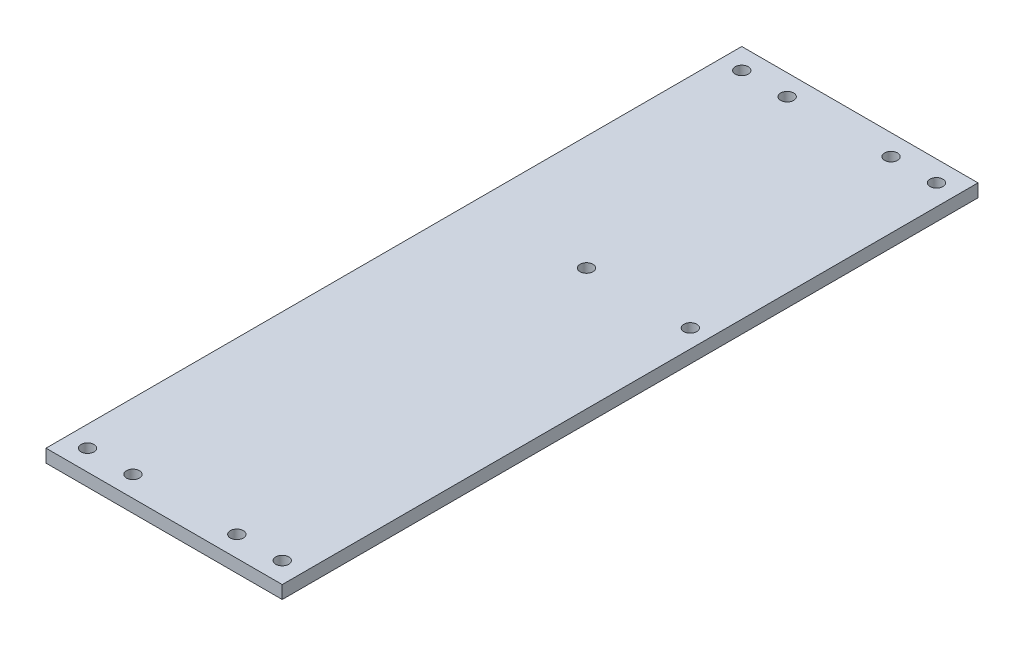
from build123d import *

# Parameters (mm, degrees)
SKIZZE1_W                       = 72.5
SKIZZE1_H                       = 268
AUFSATZ_LINEAR_AUSTRAGEN1_DEPTH = 5
M6_GEWINDEBOHRUNG2_D            = 5
M6_GEWINDEBOHRUNG2_DEPTH        = 5
M6_GEWINDEBOHRUNG1_D            = 5
M6_GEWINDEBOHRUNG1_DEPTH        = 5
SKIZZE7_W                       = 268
SKIZZE7_H                       = 5
AUFSATZ_LINEAR_AUSTRAGEN2_DEPTH = 18.5
M6_GEWINDEBOHRUNG3_D            = 5
M6_GEWINDEBOHRUNG3_DEPTH        = 5


with BuildPart() as part:
    # Skizze1 → Aufsatz-Linear austragen1 (new body)
    with BuildSketch(Plane(origin=(0, 0, 0), x_dir=(1, 0, 0), z_dir=(0, 1, 0))):
        Rectangle(SKIZZE1_W, SKIZZE1_H)
    extrude(amount=AUFSATZ_LINEAR_AUSTRAGEN1_DEPTH)

    # M6 Gewindebohrung2
    with Locations(Plane(origin=(0, 5, 0), x_dir=(1, 0, 0), z_dir=(0, 1, 0))):
        with Locations((-29.25, -126), (10.75, -126), (-29.25, 126), (10.75, 126)):
            Hole(M6_GEWINDEBOHRUNG2_D / 2, depth=M6_GEWINDEBOHRUNG2_DEPTH)

    # M6 Gewindebohrung1
    with Locations(Plane(origin=(0, 5, 0), x_dir=(1, 0, 0), z_dir=(0, 1, 0))):
        with Locations((29.25, 30.2), (-10.75, 30.2)):
            Hole(M6_GEWINDEBOHRUNG1_D / 2, depth=M6_GEWINDEBOHRUNG1_DEPTH)

    # Skizze7 → Aufsatz-Linear austragen2 (add)
    with BuildSketch(Plane.ZY.offset(36.25)):
        with Locations((0, 2.5)):
            Rectangle(SKIZZE7_W, SKIZZE7_H)
    extrude(amount=AUFSATZ_LINEAR_AUSTRAGEN2_DEPTH)

    # M6 Gewindebohrung3
    with Locations(Plane(origin=(0, 5, 0), x_dir=(1, 0, 0), z_dir=(0, 1, 0))):
        with Locations((-46.75, -126), (28.25, -126), (28.25, 126), (-46.75, 126)):
            Hole(M6_GEWINDEBOHRUNG3_D / 2, depth=M6_GEWINDEBOHRUNG3_DEPTH)


solid = part.part
